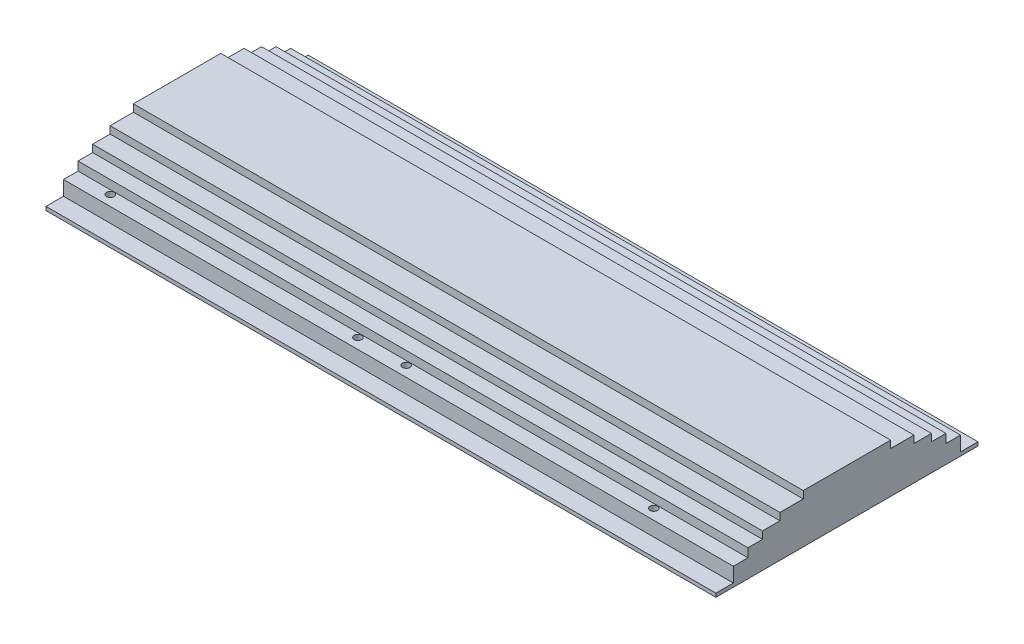
from build123d import *

# Parameters (mm, degrees)
SKETCH1_W                      = 292.1
SKETCH1_H                      = 114.3
EXTRUDE1_DEPTH                 = 1.6002
SKETCH3_W                      = 292.1
SKETCH3_H                      = 99.06
EXTRUDE2_DEPTH                 = 6.35
F_4_CLEARANCE_HOLE1_AT_2_COUNT = 2
F_4_CLEARANCE_HOLE1_AT_2_PITCH = 108.0008
F_4_CLEARANCE_HOLE1_AT_3_COUNT = 2
F_4_CLEARANCE_HOLE1_AT_3_PITCH = 140.584993512
F_4_CLEARANCE_HOLE1_AT_4_COUNT = 2
F_4_CLEARANCE_HOLE1_AT_4_PITCH = 89.99982
F_4_CLEARANCE_HOLE1_AT_5_COUNT = 2
F_4_CLEARANCE_HOLE1_AT_5_PITCH = 253.51541824
F_4_CLEARANCE_HOLE1_AT_6_COUNT = 2
F_4_CLEARANCE_HOLE1_AT_6_PITCH = 157.293864351
F_4_CLEARANCE_HOLE1_AT_7_COUNT = 2
F_4_CLEARANCE_HOLE1_AT_7_PITCH = 129.00152
F_4_CLEARANCE_HOLE1_AT_8_COUNT = 2
F_4_CLEARANCE_HOLE1_AT_8_PITCH = 237.00232
SKETCH4_W                      = 292.1
SKETCH4_H                      = 86.36
EXTRUDE3_DEPTH                 = 3.81
SKETCH5_W                      = 292.1
SKETCH5_H                      = 73.66
EXTRUDE4_DEPTH                 = 3.175
SKETCH6_W                      = 292.1
SKETCH6_H                      = 58.42
EXTRUDE5_DEPTH                 = 3.175
SKETCH7_W                      = 292.1
SKETCH7_H                      = 38.1
EXTRUDE6_DEPTH                 = 3.175
SKETCH8_R                      = 1.63195
CUT_EXTRUDE1_DEPTH             = 177.00338701


with BuildPart() as part:
    # Sketch1 → Extrude1 (new body)
    with BuildSketch(Plane(origin=(0, 0, 0), x_dir=(1, 0, 0), z_dir=(0, 1, 0))):
        with Locations((19.05, 0)):
            Rectangle(SKETCH1_W, SKETCH1_H)
    extrude(amount=EXTRUDE1_DEPTH)

    # Sketch3 → Extrude2 (add)
    with BuildSketch(Plane(origin=(0, 1.6002, 0), x_dir=(-1, 0, 0), z_dir=(0, 1, 0))):
        with Locations((-19.05, 0)):
            Rectangle(SKETCH3_W, SKETCH3_H)
    extrude(amount=EXTRUDE2_DEPTH)

    # Sketch2 → #4 Clearance Hole1 (revolve, cut)
    with BuildSketch(Plane(origin=(125.87732, 1.6002, 44.99864), x_dir=(0, 0, 1), z_dir=(1, 0, 0))):
        Polygon((0, 0), (0, 26.380574487), (1.63195, 25.4), (1.63195, 0), align=None)
    f_4_clearance_hole1 = revolve(axis=Axis((125.87732, 7.9502, 44.99864), (0, -1, 0)), mode=Mode.SUBTRACT)

    # #4 Clearance Hole1 at 2: #4 Clearance Hole1 ×2
    with Locations(*[(-i * F_4_CLEARANCE_HOLE1_AT_2_PITCH, 0, 0) for i in range(1, F_4_CLEARANCE_HOLE1_AT_2_COUNT)]):
        add(f_4_clearance_hole1, mode=Mode.SUBTRACT)

    # #4 Clearance Hole1 at 3: #4 Clearance Hole1 ×2
    with Locations(*[Vector(-0.7682242414518123, 0, -0.6401808454224382) * (i * F_4_CLEARANCE_HOLE1_AT_3_PITCH) for i in range(1, F_4_CLEARANCE_HOLE1_AT_3_COUNT)]):
        add(f_4_clearance_hole1, mode=Mode.SUBTRACT)

    # #4 Clearance Hole1 at 4: #4 Clearance Hole1 ×2
    with Locations(*[(0, 0, -i * F_4_CLEARANCE_HOLE1_AT_4_PITCH) for i in range(1, F_4_CLEARANCE_HOLE1_AT_4_COUNT)]):
        add(f_4_clearance_hole1, mode=Mode.SUBTRACT)

    # #4 Clearance Hole1 at 5: #4 Clearance Hole1 ×2
    with Locations(*[Vector(-0.9348635347125491, 0, -0.35500728367846013) * (i * F_4_CLEARANCE_HOLE1_AT_5_PITCH) for i in range(1, F_4_CLEARANCE_HOLE1_AT_5_COUNT)]):
        add(f_4_clearance_hole1, mode=Mode.SUBTRACT)

    # #4 Clearance Hole1 at 6: #4 Clearance Hole1 ×2
    with Locations(*[Vector(-0.8201306550169548, 0, -0.5721762916282541) * (i * F_4_CLEARANCE_HOLE1_AT_6_PITCH) for i in range(1, F_4_CLEARANCE_HOLE1_AT_6_COUNT)]):
        add(f_4_clearance_hole1, mode=Mode.SUBTRACT)

    # #4 Clearance Hole1 at 7: #4 Clearance Hole1 ×2
    with Locations(*[(-i * F_4_CLEARANCE_HOLE1_AT_7_PITCH, 0, 0) for i in range(1, F_4_CLEARANCE_HOLE1_AT_7_COUNT)]):
        add(f_4_clearance_hole1, mode=Mode.SUBTRACT)

    # #4 Clearance Hole1 at 8: #4 Clearance Hole1 ×2
    with Locations(*[(-i * F_4_CLEARANCE_HOLE1_AT_8_PITCH, 0, 0) for i in range(1, F_4_CLEARANCE_HOLE1_AT_8_COUNT)]):
        add(f_4_clearance_hole1, mode=Mode.SUBTRACT)

    # Sketch4 → Extrude3 (add)
    with BuildSketch(Plane(origin=(0, 7.9502, 0), x_dir=(-1, 0, 0), z_dir=(0, 1, 0))):
        with Locations((-19.05, 0)):
            Rectangle(SKETCH4_W, SKETCH4_H)
    extrude(amount=EXTRUDE3_DEPTH)

    # Sketch5 → Extrude4 (add)
    with BuildSketch(Plane(origin=(0, 11.7602, 0), x_dir=(-1, 0, 0), z_dir=(0, 1, 0))):
        with Locations((-19.05, 0)):
            Rectangle(SKETCH5_W, SKETCH5_H)
    extrude(amount=EXTRUDE4_DEPTH)

    # Sketch6 → Extrude5 (add)
    with BuildSketch(Plane(origin=(0, 14.9352, 0), x_dir=(-1, 0, 0), z_dir=(0, 1, 0))):
        with Locations((-19.05, 0)):
            Rectangle(SKETCH6_W, SKETCH6_H)
    extrude(amount=EXTRUDE5_DEPTH)

    # Sketch7 → Extrude6 (add)
    with BuildSketch(Plane(origin=(0, 18.1102, 0), x_dir=(-1, 0, 0), z_dir=(0, 1, 0))):
        with Locations((-19.05, 0)):
            Rectangle(SKETCH7_W, SKETCH7_H)
    extrude(amount=EXTRUDE6_DEPTH)

    # Sketch8 → Cut-Extrude1 (cut, through all)
    with BuildSketch(Plane.XZ):
        with Locations(Location((125.87732, -45.00118, 0), (0, 0, 90))):
            Circle(SKETCH8_R)
        with Locations(Location((17.87652, -45.00118, 0), (0, 0, 90))):
            Circle(SKETCH8_R)
        with Locations(Location((-3.1242, -45.00118, 0), (0, 0, 90))):
            Circle(SKETCH8_R)
        with Locations(Location((-111.125, -45.00118, 0), (0, 0, 90))):
            Circle(SKETCH8_R)
        with Locations(Location((-111.125, 45.00118, 0), (0, 0, 270))):
            Circle(SKETCH8_R)
        with Locations(Location((-3.1242, 45.00118, 0), (0, 0, 270))):
            Circle(SKETCH8_R)
        with Locations(Location((17.87652, 45.00118, 0), (0, 0, 270))):
            Circle(SKETCH8_R)
        with Locations(Location((125.87732, 45.00118, 0), (0, 0, 270))):
            Circle(SKETCH8_R)
    extrude(amount=-CUT_EXTRUDE1_DEPTH, mode=Mode.SUBTRACT)


solid = part.part
